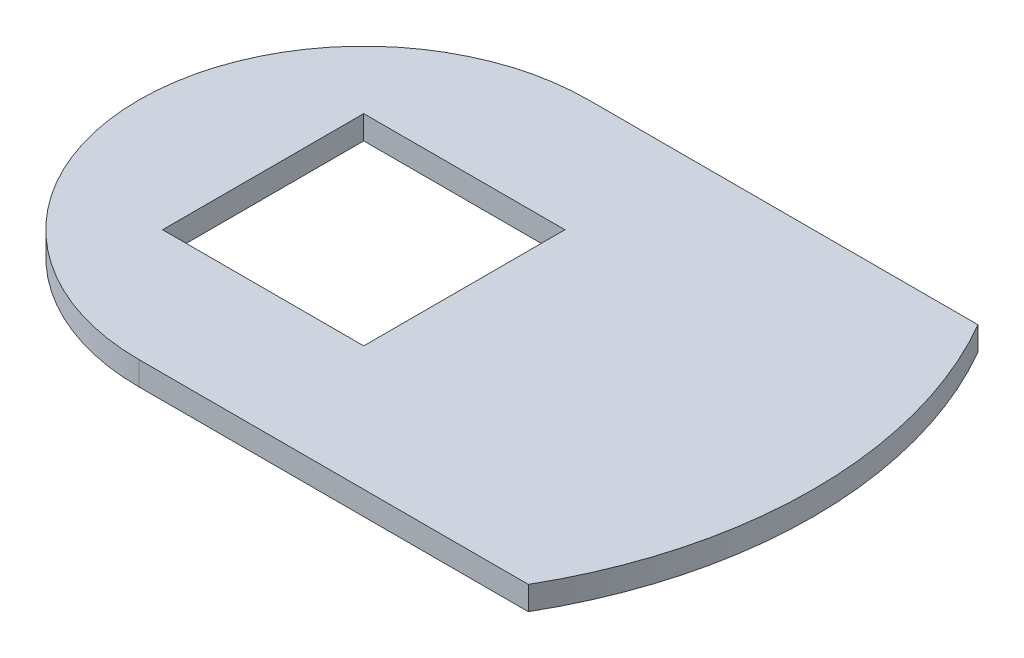
from build123d import *

# Parameters (mm, degrees)
SKIZZE1_W                       = 8.5
SKIZZE1_H                       = 8.5
AUFSATZ_LINEAR_AUSTRAGEN1_DEPTH = 1


with BuildPart() as part:
    # Skizze1 → Aufsatz-Linear austragen1 (new body)
    with BuildSketch(Plane(origin=(0, 0, 0), x_dir=(1, 0, 0), z_dir=(0, 1, 0))):
        with BuildLine():
            Line((0, -9.5), (16.454482672, -9.5))
            ThreePointArc((16.454482672, -9.5), (19, 0), (16.454482672, 9.5))
            Line((16.454482672, 9.5), (0, 9.5))
            ThreePointArc((0, 9.5), (-9.5, 0), (0, -9.5))
        make_face()
        Rectangle(SKIZZE1_W, SKIZZE1_H, mode=Mode.SUBTRACT)
    extrude(amount=AUFSATZ_LINEAR_AUSTRAGEN1_DEPTH)


solid = part.part
